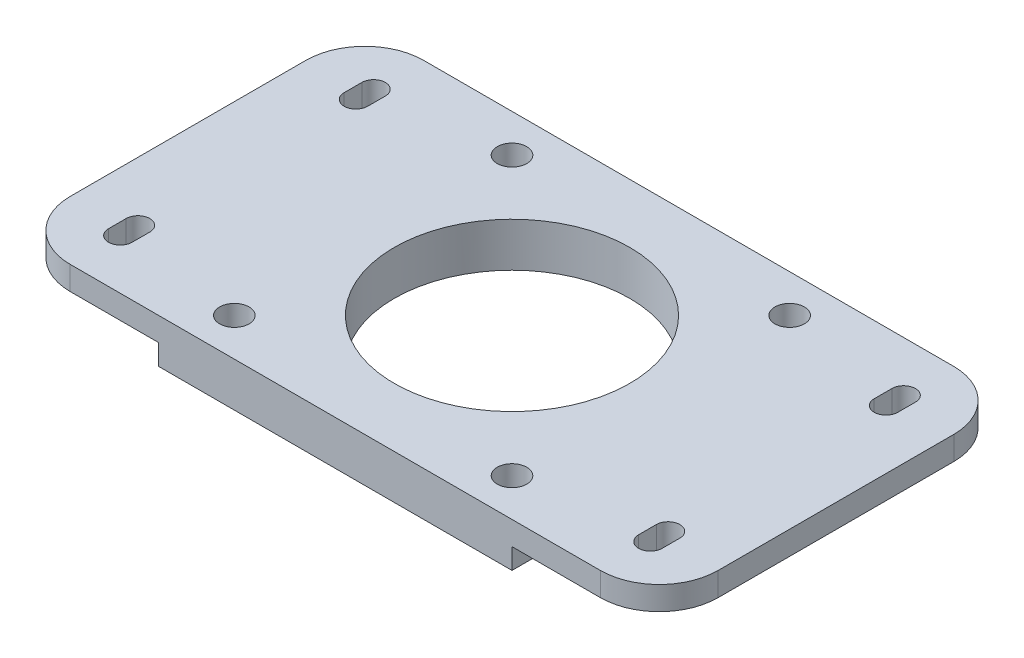
from build123d import *

# Parameters (mm, degrees)
SKETCH1_W                    = 60
SKETCH1_H                    = 60
SKETCH1_R                    = 20
BOSS_EXTRUDE1_DEPTH          = 3.5
SKETCH2_R                    = 20
BOSS_EXTRUDE2_DEPTH          = 4
F_5_0_5_DIAMETER_HOLE1_D     = 5
F_5_0_5_DIAMETER_HOLE1_DEPTH = 25
F_5_0_5_DIAMETER_HOLE1_TIP   = 1.502151548


with BuildPart() as part:
    # Sketch1 → Boss-Extrude1 (new body)
    with BuildSketch(Plane(origin=(0, 0, 0), x_dir=(1, 0, 0), z_dir=(0, 1, 0))):
        Rectangle(SKETCH1_W, SKETCH1_H)
        Circle(SKETCH1_R, mode=Mode.SUBTRACT)
    extrude(amount=BOSS_EXTRUDE1_DEPTH)

    # Sketch2 → Boss-Extrude2 (add)
    with BuildSketch(Plane(origin=(0, 3.5, -3.5), x_dir=(1, 0, 0), z_dir=(0, -1, 0))):
        with BuildLine():
            Line((45, -26.5), (-45, -26.5))
            ThreePointArc((-45, -26.5), (-52.071067812, -23.571067812), (-55, -16.5))
            Line((-55, -16.5), (-55, 23.5))
            ThreePointArc((-55, 23.5), (-52.071067812, 30.571067812), (-45, 33.5))
            Line((-45, 33.5), (45, 33.5))
            ThreePointArc((45, 33.5), (52.071067812, 30.571067812), (55, 23.5))
            Line((55, 23.5), (55, -16.5))
            ThreePointArc((55, -16.5), (52.071067812, -23.571067812), (45, -26.5))
        make_face()
        with Locations((0, 3.5)):
            Circle(SKETCH2_R, mode=Mode.SUBTRACT)
        with BuildLine():
            Line((-47, -15), (-47, -18))
            ThreePointArc((-47, -18), (-45, -20), (-43, -18))
            Line((-43, -18), (-43, -15))
            ThreePointArc((-43, -15), (-45, -13), (-47, -15))
        make_face(mode=Mode.SUBTRACT)
        with BuildLine():
            Line((-43, 25), (-43, 22))
            ThreePointArc((-43, 22), (-45, 20), (-47, 22))
            Line((-47, 22), (-47, 25))
            ThreePointArc((-47, 25), (-45, 27), (-43, 25))
        make_face(mode=Mode.SUBTRACT)
        with BuildLine():
            Line((43, -18), (43, -15))
            ThreePointArc((43, -15), (45, -13), (47, -15))
            Line((47, -15), (47, -18))
            ThreePointArc((47, -18), (45, -20), (43, -18))
        make_face(mode=Mode.SUBTRACT)
        with BuildLine():
            Line((47, 22), (47, 25))
            ThreePointArc((47, 25), (45, 27), (43, 25))
            Line((43, 25), (43, 22))
            ThreePointArc((43, 22), (45, 20), (47, 22))
        make_face(mode=Mode.SUBTRACT)
    extrude(amount=-BOSS_EXTRUDE2_DEPTH)

    # Ø5.0 (5) Diameter Hole1
    with Locations(Plane(origin=(233.298234679, 0, -449.602484579), x_dir=(-1, 0, 0), z_dir=(0, -1, 0))):
        with Locations((256.868234679, -473.172484579), (209.728234679, -473.172484579), (209.728234679, -426.032484579), (256.868234679, -426.032484579)):
            Hole(F_5_0_5_DIAMETER_HOLE1_D / 2, depth=F_5_0_5_DIAMETER_HOLE1_DEPTH)
            with Locations((0, 0, -(F_5_0_5_DIAMETER_HOLE1_DEPTH + F_5_0_5_DIAMETER_HOLE1_TIP / 2))):  # 118° drill point
                Cone(0, F_5_0_5_DIAMETER_HOLE1_D / 2, F_5_0_5_DIAMETER_HOLE1_TIP, mode=Mode.SUBTRACT)


solid = part.part
